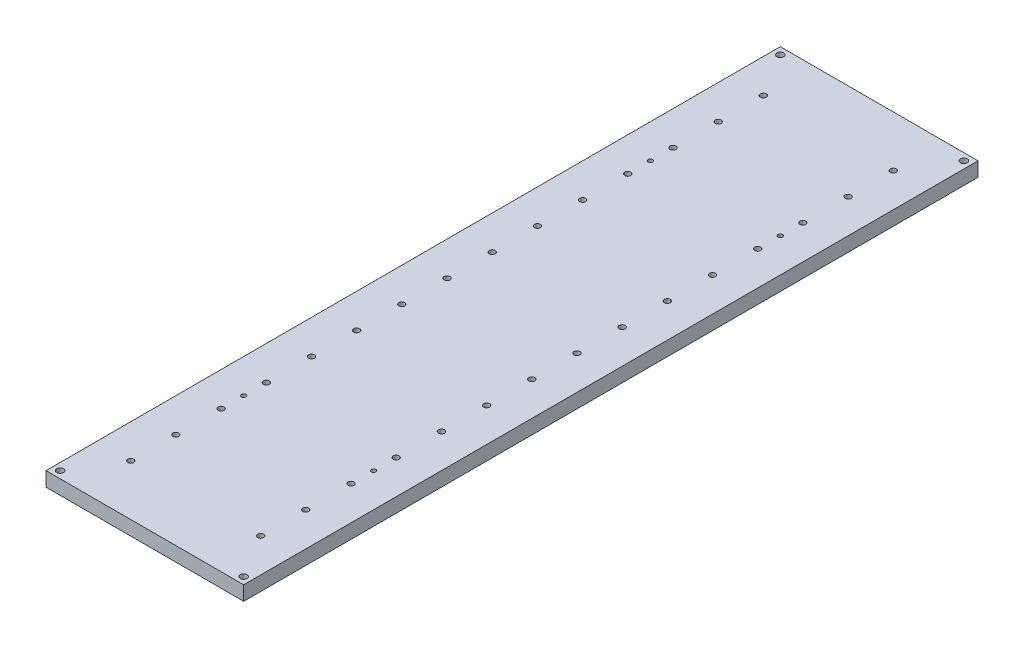
from build123d import *

# Parameters (mm, degrees)
ESBO_O1_W                                            = 264
ESBO_O1_H                                            = 25.4
RESSALTO_EXTRUS_O1_DEPTH                             = 590
ESBO_O4_W                                            = 1180
ESBO_O4_H                                            = 25.4
RESSALTO_EXTRUS_O3_DEPTH                             = 43
ESBO_O3_W                                            = 1180
ESBO_O3_H                                            = 25.4
RESSALTO_EXTRUS_O4_DEPTH                             = 43
REBAIXO_PARA_PARAFUSO_ALLEN_SEXTAVADO_DE_D           = 10.5
REBAIXO_PARA_PARAFUSO_ALLEN_SEXTAVADO_DE_CBORE_D     = 18
REBAIXO_PARA_PARAFUSO_ALLEN_SEXTAVADO_DE_CBORE_DEPTH = 10.6
ESBO_O7_R                                            = 4
CORTE_EXTRUS_O1_DEPTH                                = 26.4
PADR_O_LINEAR1_COUNT                                 = 2
PADR_O_LINEAR1_PITCH                                 = 720
ESBO_O9_W                                            = 350
ESBO_O9_H                                            = 25.4
RESSALTO_EXTRUS_O5_DEPTH                             = 60
ESBO_O10_W                                           = 350
ESBO_O10_H                                           = 25.4
RESSALTO_EXTRUS_O6_DEPTH                             = 60
ESBO_O15_R                                           = 3
CORTE_EXTRUS_O2_DEPTH                                = 26.4
ESBO_O20_R                                           = 6
CORTE_EXTRUS_O4_DEPTH                                = 10


with BuildPart() as part:
    # Esboço1 → Ressalto-extrusão1 (new body, symmetric)
    with BuildSketch(Plane.XY):
        Rectangle(ESBO_O1_W, ESBO_O1_H)
    extrude(amount=RESSALTO_EXTRUS_O1_DEPTH, both=True)

    # Esboço4 → Ressalto-extrusão3 (add)
    with BuildSketch(Plane.ZY.offset(132)):
        Rectangle(ESBO_O4_W, ESBO_O4_H)
    extrude(amount=RESSALTO_EXTRUS_O3_DEPTH)

    # Esboço3 → Ressalto-extrusão4 (add)
    with BuildSketch(Plane(origin=(132, 0, 0), x_dir=(0, 0, -1), z_dir=(1, 0, 0))):
        Rectangle(ESBO_O3_W, ESBO_O3_H)
    extrude(amount=RESSALTO_EXTRUS_O4_DEPTH)

    # Rebaixo para parafuso Allen sextavado de M101 (through all)
    with Locations(Plane(origin=(0, -12.7, 0), x_dir=(-1, 0, 0), z_dir=(0, -1, 0))):
        with Locations((115, -320), (115, -240), (-115, 400), (-115, 240), (-115, 80), (-115, -80), (-115, -240), (-115, -400), (115, -480), (-115, -320), (-115, -160), (-115, 0), (-115, 160), (-115, 320), (-115, 480), (-115, 560), (115, 560), (-115, -480), (115, -400), (115, -80), (115, 0), (115, 80), (115, 160), (115, 320), (115, 240), (115, 400), (115, 480), (115, -160), (115, -560), (-115, -560)):
            CounterBoreHole(REBAIXO_PARA_PARAFUSO_ALLEN_SEXTAVADO_DE_D / 2, REBAIXO_PARA_PARAFUSO_ALLEN_SEXTAVADO_DE_CBORE_D / 2, REBAIXO_PARA_PARAFUSO_ALLEN_SEXTAVADO_DE_CBORE_DEPTH)

    # Esboço7 → Corte-extrusão1 (cut, through all)
    with BuildSketch(Plane.XZ.offset(12.7)):
        with Locations((-115, 360)):
            Circle(ESBO_O7_R)
        with Locations((115, 360)):
            Circle(ESBO_O7_R)
    corte_extrus_o1 = extrude(amount=-CORTE_EXTRUS_O1_DEPTH, mode=Mode.SUBTRACT)

    # Padrão linear1: Corte-extrusão1 ×2
    with Locations(*[(0, 0, -i * PADR_O_LINEAR1_PITCH) for i in range(1, PADR_O_LINEAR1_COUNT)]):
        add(corte_extrus_o1, mode=Mode.SUBTRACT)

    # Esboço9 → Ressalto-extrusão5 (add)
    with BuildSketch(Plane.XY.offset(590)):
        Rectangle(ESBO_O9_W, ESBO_O9_H)
    extrude(amount=RESSALTO_EXTRUS_O5_DEPTH)

    # Esboço10 → Ressalto-extrusão6 (add)
    with BuildSketch(Plane(origin=(0, 0, -590), x_dir=(-1, 0, 0), z_dir=(0, 0, -1))):
        Rectangle(ESBO_O10_W, ESBO_O10_H)
    extrude(amount=RESSALTO_EXTRUS_O6_DEPTH)

    # Esboço15 → Corte-extrusão2 (cut, through all)
    with BuildSketch(Plane(origin=(0, 12.7, 0), x_dir=(1, 0, 0), z_dir=(0, 1, 0))):
        with Locations((-162.5, -637.5)):
            Circle(ESBO_O15_R)
        with Locations((162.5, -637.5)):
            Circle(ESBO_O15_R)
        with Locations((-162.5, 637.5)):
            Circle(ESBO_O15_R)
        with Locations((162.5, 637.5)):
            Circle(ESBO_O15_R)
    extrude(amount=-CORTE_EXTRUS_O2_DEPTH, mode=Mode.SUBTRACT)

    # Esboço20 → Corte-extrusão4 (cut)
    with BuildSketch(Plane(origin=(0, 12.7, 0), x_dir=(1, 0, 0), z_dir=(0, 1, 0))):
        with Locations((-162.5, -637.5)):
            Circle(ESBO_O20_R)
        with Locations((162.5, -637.5)):
            Circle(ESBO_O20_R)
        with Locations((-162.5, 637.5)):
            Circle(ESBO_O20_R)
        with Locations((162.5, 637.5)):
            Circle(ESBO_O20_R)
    extrude(amount=-CORTE_EXTRUS_O4_DEPTH, mode=Mode.SUBTRACT)


solid = part.part
